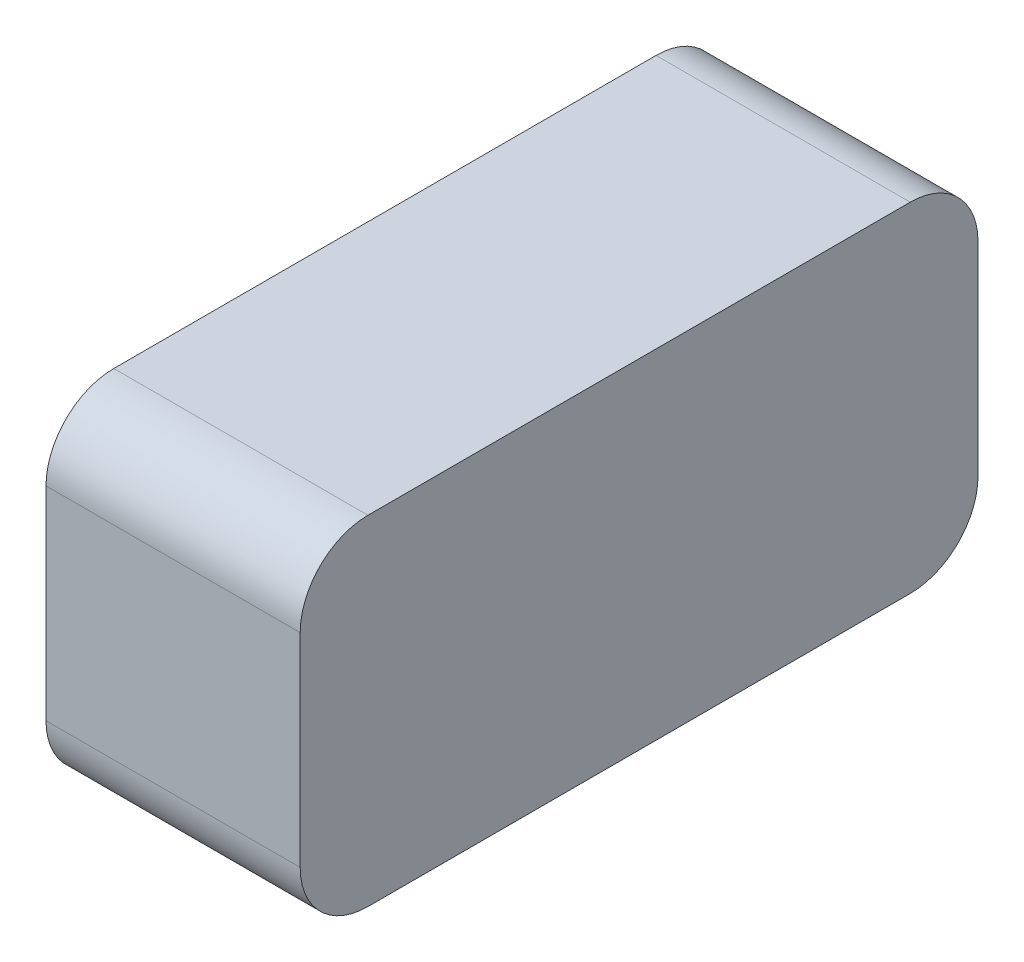
from build123d import *

# Parameters (mm, degrees)
SKETCH1_W           = 80
SKETCH1_H           = 40
BOSS_EXTRUDE1_DEPTH = 15
FILLET1_R           = 8
SKETCH2_R           = 10
BOSS_EXTRUDE2_DEPTH = 5
FILLET2_R           = 3


with BuildPart() as part:
    # Sketch1 → Boss-Extrude1 (new body, symmetric)
    with BuildSketch(Plane(origin=(0, 0, 0), x_dir=(0, 0, -1), z_dir=(1, 0, 0))):
        Rectangle(SKETCH1_W, SKETCH1_H)
    extrude(amount=BOSS_EXTRUDE1_DEPTH, both=True)

    # Fillet1
    fillet1_edges = [part.edges().sort_by_distance(p)[0] for p in [
        (0, -20, -40),
        (0, -20, 40),
        (0, 20, 40),
        (0, 20, -40),
    ]]
    fillet(fillet1_edges, radius=FILLET1_R)

    # Sketch2 → Boss-Extrude2 (add)
    with BuildSketch(Plane.ZY.offset(15)):
        Circle(SKETCH2_R)
    extrude(amount=BOSS_EXTRUDE2_DEPTH)

    # Fillet2
    fillet2_edges = [part.edges().sort_by_distance(p)[0] for p in [
        (-15, 0, -10),
    ]]
    fillet(fillet2_edges, radius=FILLET2_R)


solid = part.part
